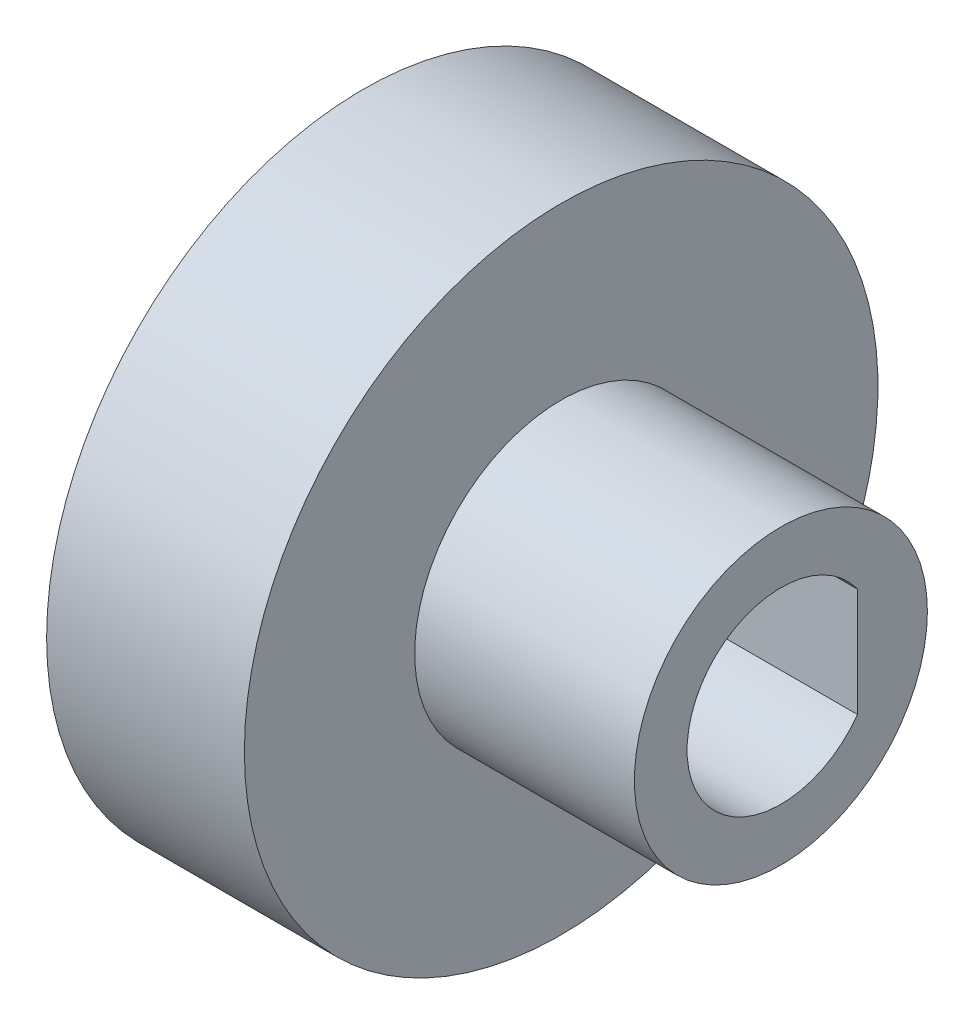
from build123d import *

# Parameters (mm, degrees)
SKETCH1_R           = 5.08
BOSS_EXTRUDE1_DEPTH = 7.62
SKETCH2_R           = 10.9855
BOSS_EXTRUDE2_DEPTH = 6.858
CUT_EXTRUDE1_REACH  = 16.478


with BuildPart() as part:
    # Sketch1 → Boss-Extrude1 (new body)
    with BuildSketch(Plane(origin=(0, 0, 0), x_dir=(0, 0, -1), z_dir=(1, 0, 0))):
        Circle(SKETCH1_R)
    extrude(amount=BOSS_EXTRUDE1_DEPTH)

    # Sketch2 → Boss-Extrude2 (add)
    with BuildSketch(Plane.ZY):
        Circle(SKETCH2_R)
    extrude(amount=BOSS_EXTRUDE2_DEPTH)

    # Sketch3 → Cut-Extrude1 (cut, up to next)
    with BuildSketch(Plane.ZY.offset(6.858), mode=Mode.PRIVATE) as cut_extrude1_sk1:
        with BuildLine():
            Line((-2.654, -1.882763926), (-2.654, 1.882763926))
            ThreePointArc((-2.654, 1.882763926), (3.254, 0), (-2.654, -1.882763926))
        make_face()
    cut_extrude1_tool1 = extrude(cut_extrude1_sk1.sketch, amount=-CUT_EXTRUDE1_REACH, mode=Mode.PRIVATE) & part.part
    add(cut_extrude1_tool1.solids().sort_by_distance((-6.858, 0, 0.140232))[0], mode=Mode.SUBTRACT)


solid = part.part
